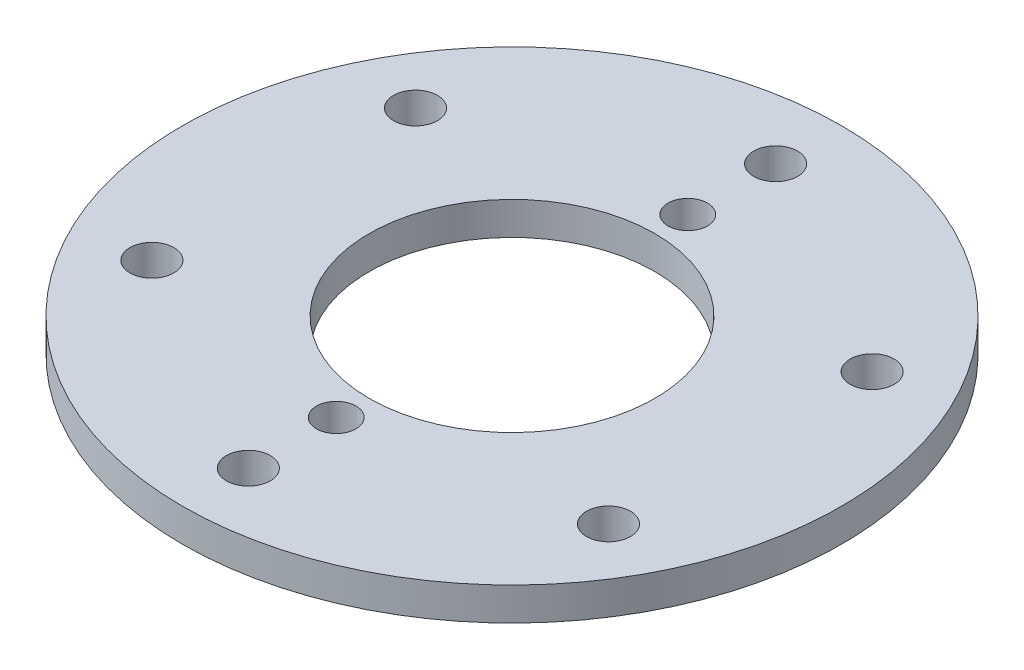
from build123d import *

# Parameters (mm, degrees)
SKETCH1_R           = 150
SKETCH1_R_2         = 65
SKETCH1_R_3         = 10
SKETCH1_R_4         = 9
BOSS_EXTRUDE1_DEPTH = 15


with BuildPart() as part:
    # Sketch1 → Boss-Extrude1 (new body)
    with BuildSketch(Plane(origin=(0, 0, 0), x_dir=(1, 0, 0), z_dir=(0, 1, 0))):
        Circle(SKETCH1_R)
        Circle(SKETCH1_R_2, mode=Mode.SUBTRACT)
        with Locations((0, 120)):
            Circle(SKETCH1_R_3, mode=Mode.SUBTRACT)
        with Locations((0, 80)):
            Circle(SKETCH1_R_4, mode=Mode.SUBTRACT)
        with Locations((103.923048454, 60)):
            Circle(SKETCH1_R_3, mode=Mode.SUBTRACT)
        with Locations((103.923048454, -60)):
            Circle(SKETCH1_R_3, mode=Mode.SUBTRACT)
        with Locations((0, -120)):
            Circle(SKETCH1_R_3, mode=Mode.SUBTRACT)
        with Locations((-103.923048454, -60)):
            Circle(SKETCH1_R_3, mode=Mode.SUBTRACT)
        with Locations((-103.923048454, 60)):
            Circle(SKETCH1_R_3, mode=Mode.SUBTRACT)
        with Locations((0, -80)):
            Circle(SKETCH1_R_4, mode=Mode.SUBTRACT)
    extrude(amount=BOSS_EXTRUDE1_DEPTH)


solid = part.part
